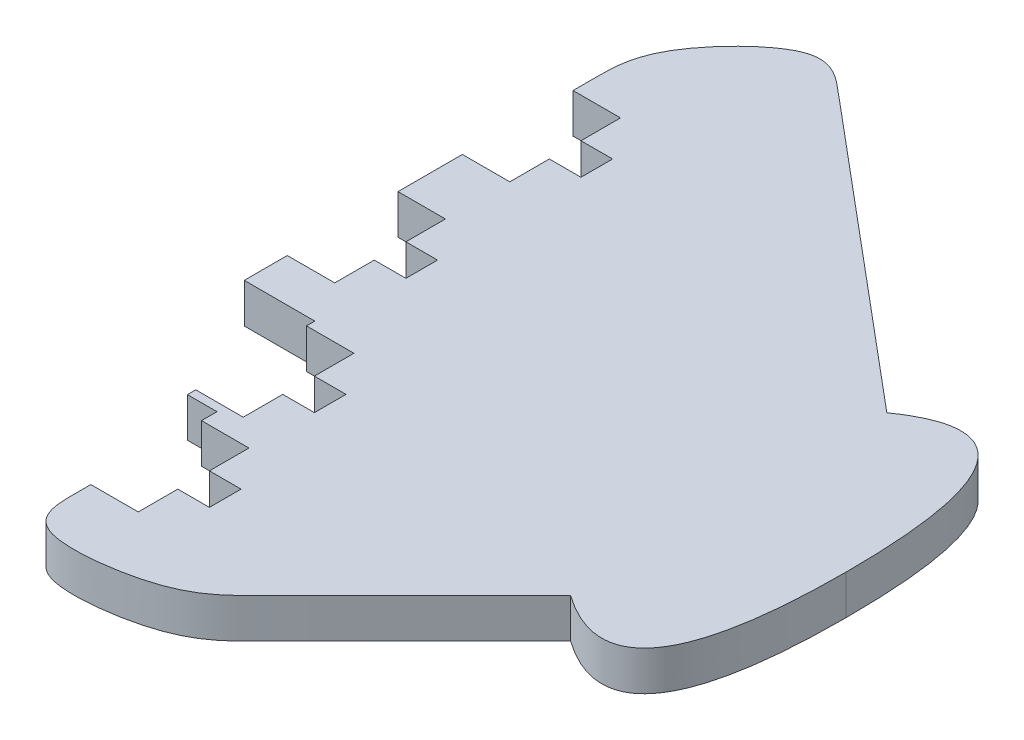
from build123d import *

# Parameters (mm, degrees)
BOSS_EXTRUDE1_DEPTH = 5


with BuildPart() as part:
    # Sketch1 → Boss-Extrude1 (new body)
    with BuildSketch(Plane(origin=(0, 0, 0), x_dir=(1, 0, 0), z_dir=(0, 1, 0))):
        with BuildLine():
            Line((-0.215430266, -7.177757881), (-0.215430266, -12.177757881))
            Line((-0.215430266, -12.177757881), (3.784569734, -12.177757881))
            Line((3.784569734, -12.177757881), (3.784569734, -16.177757881))
            Line((3.784569734, -16.177757881), (-0.215430266, -16.177757881))
            Line((-0.215430266, -16.177757881), (-0.215430266, -21.177757881))
            Line((-0.215430266, -21.177757881), (-6.215430266, -21.177757881))
            Line((-6.215430266, -21.177757881), (-6.215430266, -22.231309316))
            Line((-6.215430266, -22.231309316), (-2.476053015, -22.231309316))
            Line((-2.476053015, -22.231309316), (-2.476053015, -24.19082993))
            Line((-2.476053015, -24.19082993), (3.523946985, -24.19082993))
            Line((3.523946985, -24.19082993), (3.523946985, -29.19082993))
            Line((3.523946985, -29.19082993), (7.523946985, -29.19082993))
            Line((7.523946985, -29.19082993), (7.523946985, -33.19082993))
            Line((7.523946985, -33.19082993), (3.523946985, -33.19082993))
            Line((3.523946985, -33.19082993), (3.523946985, -38.19082993))
            Line((3.523946985, -38.19082993), (-2.476053015, -38.19082993))
            add(Edge.make_bspline(
                [(-2.476053015, -38.19082993), (-2.476053015, -38.844003468), (-2.476053015, -39.497177007), (-2.476053015, -40.150350545), (-2.476053015, -42.630984152), (-2.476053015, -47.592251368), (14.587430918, -45.412569082), (18.09557661, -41.90442339), (19.849649455, -40.150350545), (26.56643297, -33.43356703), (33.283216485, -26.716783515), (40, -20)],
                knots=[0, 0, 0, 0, 0.037124703, 0.037124703, 0.037124703, 0.178117534, 0.319110365, 0.460103196, 0.460103196, 0.460103196, 1, 1, 1, 1], degree=3))
            add(Edge.make_bspline(
                [(54.864590085, 0), (54.864590085, -30.55331743), (40, -20)],
                knots=[0, 0, 0, 1, 1, 1], degree=2))
            add(Edge.make_bspline(
                [(54.864590085, 0), (54.864590085, 30.55331743), (40, 20)],
                knots=[0, 0, 0, 1, 1, 1], degree=2))
            add(Edge.make_bspline(
                [(40, 20), (27.232592615, 30.713126828), (14.465185229, 41.426253656), (1.697777844, 52.139380484), (-0.164978248, 53.702418434), (-3.890490433, 56.828494334), (-15.135409915, 45.448905299), (-15.135409915, 40.585594537), (-15.135409915, 38.153939156), (-15.135409915, 37.254356542), (-15.135409915, 36.354773928), (-15.135409915, 35.455191313)],
                knots=[0, 0, 0, 0, 0.670388249, 0.670388249, 0.670388249, 0.76819744, 0.866006632, 0.963815823, 0.963815823, 0.963815823, 1, 1, 1, 1], degree=3))
            Line((-15.135409915, 35.455191313), (-9.135409915, 35.455191313))
            Line((-9.135409915, 35.455191313), (-9.135409915, 30.455191313))
            Line((-9.135409915, 30.455191313), (-5.135409915, 30.455191313))
            Line((-5.135409915, 30.455191313), (-5.135409915, 26.455191313))
            Line((-5.135409915, 26.455191313), (-9.135409915, 26.455191313))
            Line((-9.135409915, 26.455191313), (-9.135409915, 21.455191313))
            Line((-9.135409915, 21.455191313), (-15.135409915, 21.455191313))
            Line((-15.135409915, 21.455191313), (-15.135409915, 18.75644347))
            Line((-15.135409915, 18.75644347), (-15.135409915, 13.316118512))
            Line((-15.135409915, 13.316118512), (-9.135409915, 13.316118512))
            Line((-9.135409915, 13.316118512), (-9.135409915, 8.316118512))
            Line((-9.135409915, 8.316118512), (-5.135409915, 8.316118512))
            Line((-5.135409915, 8.316118512), (-5.135409915, 4.316118512))
            Line((-5.135409915, 4.316118512), (-9.135409915, 4.316118512))
            Line((-9.135409915, 4.316118512), (-9.135409915, -0.683881488))
            Line((-9.135409915, -0.683881488), (-15.135409915, -0.683881488))
            Line((-15.135409915, -0.683881488), (-15.135409915, -6.124206447))
            Line((-15.135409915, -6.124206447), (-6.215430266, -6.124206447))
            Line((-6.215430266, -6.124206447), (-6.215430266, -7.177757881))
            Line((-6.215430266, -7.177757881), (-0.215430266, -7.177757881))
        make_face()
    extrude(amount=BOSS_EXTRUDE1_DEPTH)


solid = part.part
